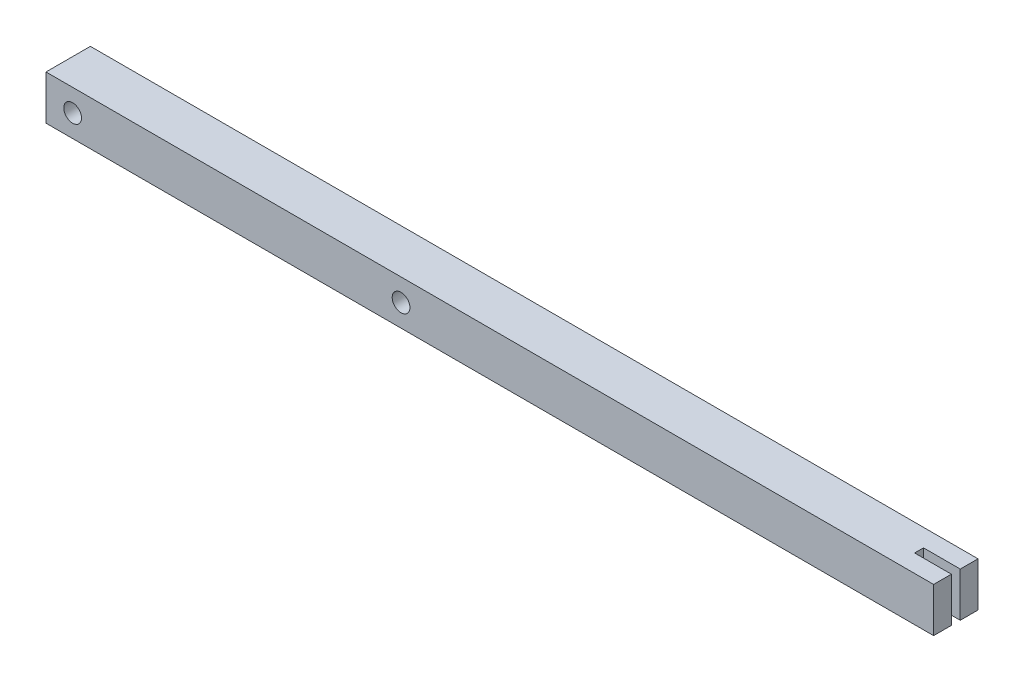
from build123d import *

# Parameters (mm, degrees)
SKETCH1_W           = 500
SKETCH1_H           = 25
BOSS_EXTRUDE1_DEPTH = 25
SKETCH2_R           = 5
CUT_EXTRUDE1_DEPTH  = 25
SKETCH5_W           = 20.75
SKETCH5_H           = 5
CUT_EXTRUDE2_DEPTH  = 25


with BuildPart() as part:
    # Sketch1 → Boss-Extrude1 (new body)
    with BuildSketch(Plane(origin=(0, 0, 0), x_dir=(1, 0, 0), z_dir=(0, 1, 0))):
        Rectangle(SKETCH1_W, SKETCH1_H)
    extrude(amount=BOSS_EXTRUDE1_DEPTH)

    # Sketch2 → Cut-Extrude1 (cut)
    with BuildSketch(Plane.XY.offset(12.5)):
        with Locations((-235, 12.5)):
            Circle(SKETCH2_R)
        with Locations((-50, 12.5)):
            Circle(SKETCH2_R)
    extrude(amount=-CUT_EXTRUDE1_DEPTH, mode=Mode.SUBTRACT)

    # Sketch5 → Cut-Extrude2 (cut)
    with BuildSketch(Plane(origin=(0, 25, 0), x_dir=(1, 0, 0), z_dir=(0, 1, 0))):
        with Locations((239.670802425, 0)):
            Rectangle(SKETCH5_W, SKETCH5_H)
    extrude(amount=-CUT_EXTRUDE2_DEPTH, mode=Mode.SUBTRACT)


solid = part.part
